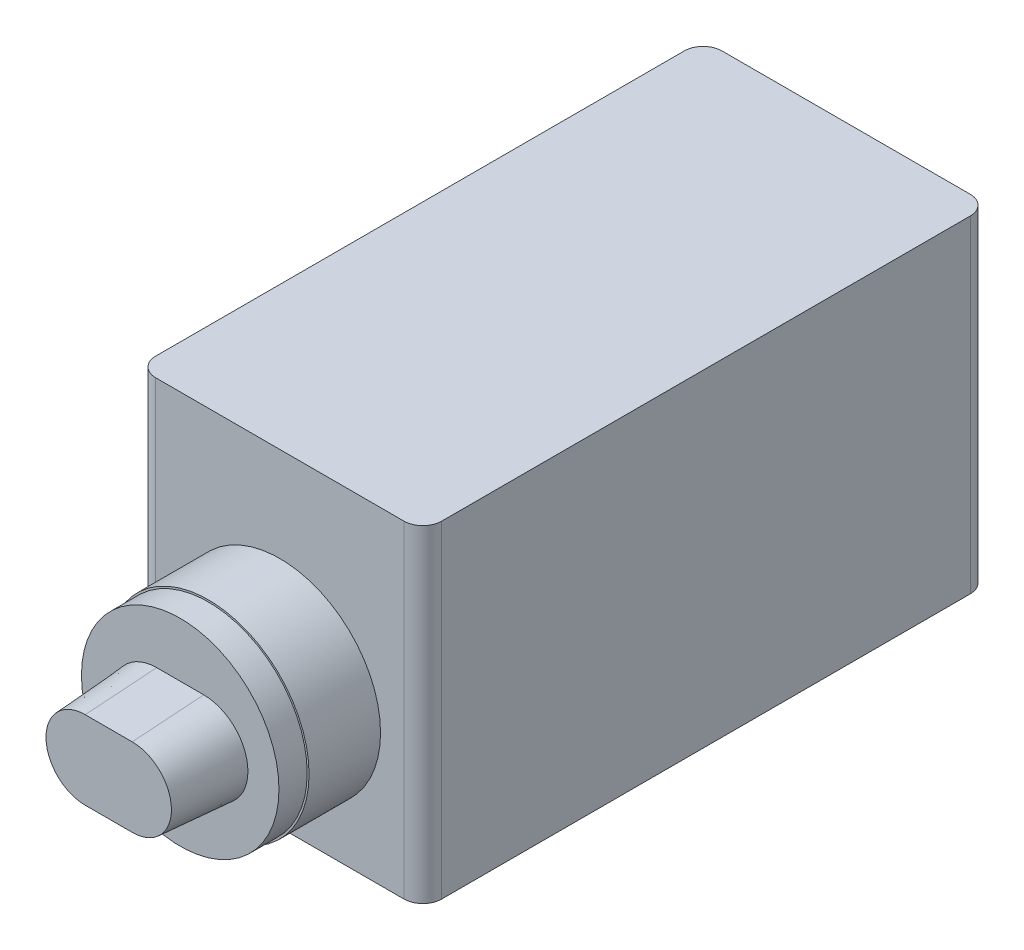
from build123d import *

# Parameters (mm, degrees)
SKETCH1_W           = 15.2
SKETCH1_H           = 30.1
BOSS_EXTRUDE1_DEPTH = 17.4
FILLET1_R           = 1
SKETCH3_R           = 5.35
BOSS_EXTRUDE2_DEPTH = 3.8
SKETCH4_R           = 5.25
BOSS_EXTRUDE3_DEPTH = 1.5
BOSS_EXTRUDE4_DEPTH = 3.8
BOSS_EXTRUDE4_TAPER = 4


with BuildPart() as part:
    # Sketch1 → Boss-Extrude1 (new body)
    with BuildSketch(Plane(origin=(0, 0, 0), x_dir=(1, 0, 0), z_dir=(0, 1, 0))):
        Rectangle(SKETCH1_W, SKETCH1_H)
    extrude(amount=BOSS_EXTRUDE1_DEPTH)

    # Fillet1
    fillet1_edges = [part.edges().sort_by_distance(p)[0] for p in [
        (-7.6, 8.7, -15.05),
        (7.6, 8.7, -15.05),
        (7.6, 8.7, 15.05),
        (-7.6, 8.7, 15.05),
    ]]
    fillet(fillet1_edges, radius=FILLET1_R)

    # Sketch3 → Boss-Extrude2 (add)
    with BuildSketch(Plane.XY.offset(15.05)):
        with Locations((0, 7.030745518)):
            Circle(SKETCH3_R)
    extrude(amount=BOSS_EXTRUDE2_DEPTH)

    # Sketch4 → Boss-Extrude3 (add)
    with BuildSketch(Plane.XY.offset(18.85)):
        with Locations((0, 7.030745518)):
            Circle(SKETCH4_R)
    extrude(amount=BOSS_EXTRUDE3_DEPTH)

    # Sketch5 → Boss-Extrude4 (add)
    with BuildSketch(Plane.XY.offset(20.35)):
        with BuildLine():
            ThreePointArc((-1.25, 9.380745518), (-3.6, 7.030745518), (-1.25, 4.680745518))
            Line((-1.25, 4.680745518), (1.25, 4.680745518))
            ThreePointArc((1.25, 4.680745518), (3.6, 7.030745518), (1.25, 9.380745518))
            Line((1.25, 9.380745518), (-1.25, 9.380745518))
        make_face()
    extrude(amount=BOSS_EXTRUDE4_DEPTH, taper=BOSS_EXTRUDE4_TAPER)


solid = part.part
